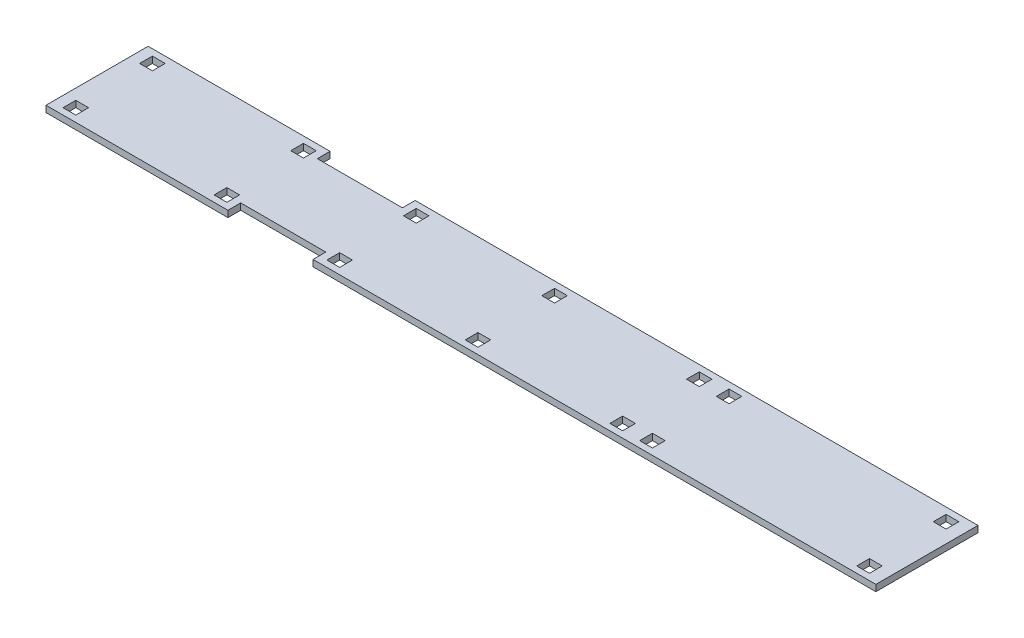
from build123d import *

# Parameters (mm, degrees)
SKETCH1_W           = 195
SKETCH1_H           = 24
SKETCH1_W_2         = 3
SKETCH1_H_2         = 3
BOSS_EXTRUDE1_DEPTH = 1.5
SKETCH2_W           = 20
SKETCH2_H           = 3
CUT_EXTRUDE1_DEPTH  = 1.5


with BuildPart() as part:
    # Sketch1 → Boss-Extrude1 (new body)
    with BuildSketch(Plane(origin=(0, 0, 0), x_dir=(1, 0, 0), z_dir=(0, 1, 0))):
        with Locations((97.5, 12)):
            Rectangle(SKETCH1_W, SKETCH1_H)
        with Locations((66, 3)):
            Rectangle(SKETCH1_W_2, SKETCH1_H_2, mode=Mode.SUBTRACT)
        with Locations((4, 21)):
            Rectangle(SKETCH1_W_2, SKETCH1_H_2, mode=Mode.SUBTRACT)
        with Locations((39.5, 3)):
            Rectangle(SKETCH1_W_2, SKETCH1_H_2, mode=Mode.SUBTRACT)
        with Locations((98.5, 3)):
            Rectangle(SKETCH1_W_2, SKETCH1_H_2, mode=Mode.SUBTRACT)
        with Locations((139.5, 3)):
            Rectangle(SKETCH1_W_2, SKETCH1_H_2, mode=Mode.SUBTRACT)
        with Locations((139.5, 21)):
            Rectangle(SKETCH1_W_2, SKETCH1_H_2, mode=Mode.SUBTRACT)
        with Locations((132.5, 3)):
            Rectangle(SKETCH1_W_2, SKETCH1_H_2, mode=Mode.SUBTRACT)
        with Locations((132.5, 21)):
            Rectangle(SKETCH1_W_2, SKETCH1_H_2, mode=Mode.SUBTRACT)
        with Locations((66, 21)):
            Rectangle(SKETCH1_W_2, SKETCH1_H_2, mode=Mode.SUBTRACT)
        with Locations((98.5, 21)):
            Rectangle(SKETCH1_W_2, SKETCH1_H_2, mode=Mode.SUBTRACT)
        with Locations((39.5, 21)):
            Rectangle(SKETCH1_W_2, SKETCH1_H_2, mode=Mode.SUBTRACT)
        with Locations((4, 3)):
            Rectangle(SKETCH1_W_2, SKETCH1_H_2, mode=Mode.SUBTRACT)
        with Locations((190.5, 21)):
            Rectangle(SKETCH1_W_2, SKETCH1_H_2, mode=Mode.SUBTRACT)
        with Locations((190.5, 3)):
            Rectangle(SKETCH1_W_2, SKETCH1_H_2, mode=Mode.SUBTRACT)
    extrude(amount=BOSS_EXTRUDE1_DEPTH)

    # Sketch2 → Cut-Extrude1 (cut)
    with BuildSketch(Plane(origin=(0, 1.5, 0), x_dir=(1, 0, 0), z_dir=(0, 1, 0))):
        with Locations((52.75, 1.5)):
            Rectangle(SKETCH2_W, SKETCH2_H)
        with Locations((52.75, 22.5)):
            Rectangle(SKETCH2_W, SKETCH2_H)
    extrude(amount=-CUT_EXTRUDE1_DEPTH, mode=Mode.SUBTRACT)


solid = part.part
